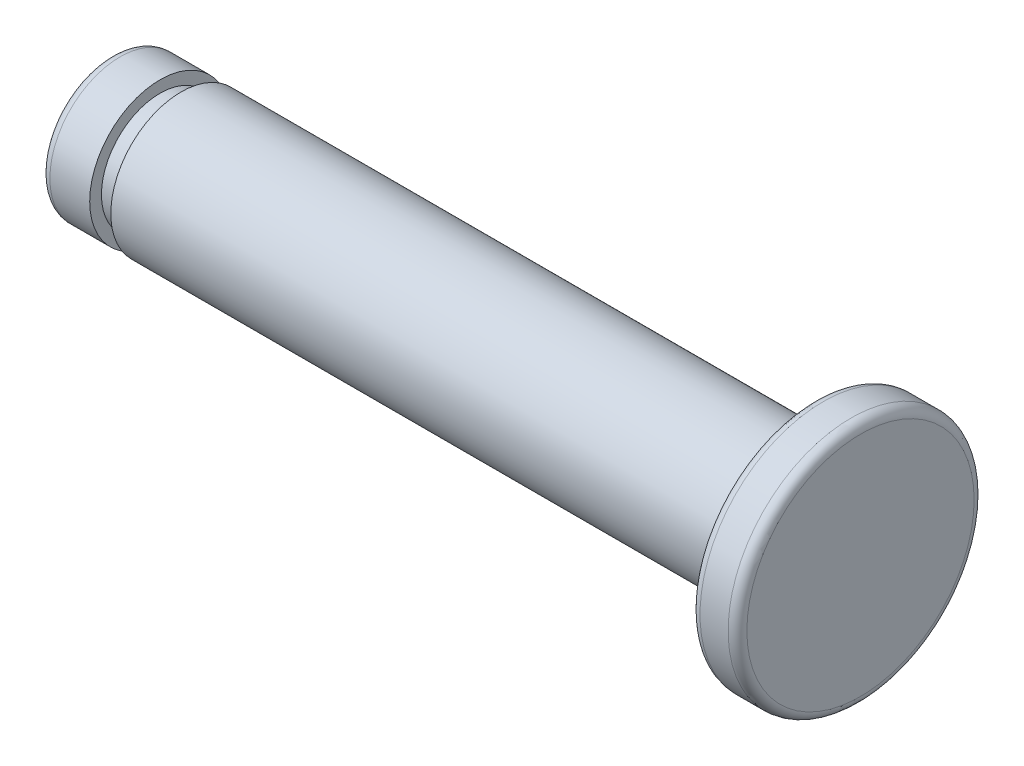
from build123d import *

# Parameters (mm, degrees)
SKETCH_1_R      = 5.25
EXTRUDE_1_DEPTH = 2
SKETCH_1_4_R    = 3
EXTRUDE_2_DEPTH = 27
FILLET_1_R      = 0.4
SKETCH_2_R      = 2.5
EXTRUDE_3_DEPTH = 0.9
SKETCH_3_R      = 3
EXTRUDE_4_DEPTH = 2.1
FILLET_2_R      = 0.4


with BuildPart() as part:
    # 草图1 → 凸台-拉伸1 (new body)
    with BuildSketch(Plane(origin=(0, 0, 0), x_dir=(0, 0, -1), z_dir=(1, 0, 0))):
        Circle(SKETCH_1_R)
    extrude(amount=EXTRUDE_1_DEPTH)

    # 草图1<4> → 凸台-拉伸2 (add)
    with BuildSketch(Plane(origin=(0, 0, 0), x_dir=(0, 0, -1), z_dir=(1, 0, 0))):
        Circle(SKETCH_1_4_R)
    extrude(amount=-EXTRUDE_2_DEPTH)

    # 圆角1
    fillet_1_edges = [part.edges().sort_by_distance(p)[0] for p in [
        (2, 0, 5.25),
        (0, 0, 5.25),
    ]]
    fillet(fillet_1_edges, radius=FILLET_1_R)

    # 草图2 → 凸台-拉伸3 (add)
    with BuildSketch(Plane.ZY.offset(27)):
        Circle(SKETCH_2_R)
    extrude(amount=EXTRUDE_3_DEPTH)

    # 草图3 → 凸台-拉伸4 (add)
    with BuildSketch(Plane.ZY.offset(27.9)):
        Circle(SKETCH_3_R)
    extrude(amount=EXTRUDE_4_DEPTH)

    # 圆角2
    fillet_2_edges = [part.edges().sort_by_distance(p)[0] for p in [
        (-30, 0, -3),
    ]]
    fillet(fillet_2_edges, radius=FILLET_2_R)


solid = part.part
